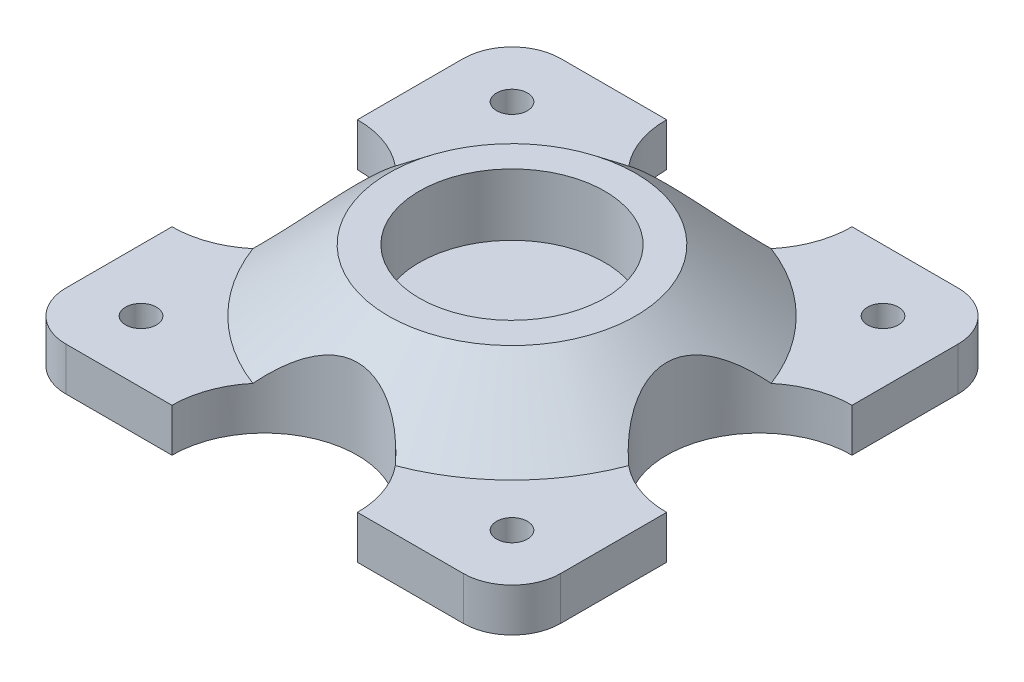
from build123d import *

# Parameters (mm, degrees)
BOSS_EXTRUDE1_DEPTH = 8.89
SKETCH3_R           = 19.05
SKETCH3_R_2         = 3.175
CUT_EXTRUDE1_DEPTH  = 22.59
SKETCH4_R           = 19.05
BOSS_EXTRUDE3_DEPTH = 8.89


with BuildPart() as part:
    # Sketch1 → Boss-Extrude1 (new body)
    with BuildSketch(Plane(origin=(0, 0, 0), x_dir=(1, 0, 0), z_dir=(0, 1, 0))):
        with BuildLine():
            Line((40.8, 50.8), (-40.8, 50.8))
            ThreePointArc((-40.8, 50.8), (-47.871067812, 47.871067812), (-50.8, 40.8))
            Line((-50.8, 40.8), (-50.8, -40.8))
            ThreePointArc((-50.8, -40.8), (-47.871067812, -47.871067812), (-40.8, -50.8))
            Line((-40.8, -50.8), (40.8, -50.8))
            ThreePointArc((40.8, -50.8), (47.871067812, -47.871067812), (50.8, -40.8))
            Line((50.8, -40.8), (50.8, 40.8))
            ThreePointArc((50.8, 40.8), (47.871067812, 47.871067812), (40.8, 50.8))
        make_face()
    extrude(amount=BOSS_EXTRUDE1_DEPTH)

    # Sketch2 → Revolve1 (revolve)
    with BuildSketch(Plane.XY):
        Polygon((0, 8.89), (0, 21.59), (-25.4, 21.59), (-41.28, 8.89), align=None)
    revolve(axis=Axis((0, 8.89, 0), (0, 1, 0)))

    # Sketch3 → Cut-Extrude1 (cut, through all)
    with BuildSketch(Plane(origin=(0, 21.59, 0), x_dir=(1, 0, 0), z_dir=(0, 1, 0))):
        Circle(SKETCH3_R)
        with Locations((-38.1, 38.1)):
            Circle(SKETCH3_R_2)
        with Locations((38.1, 38.1)):
            Circle(SKETCH3_R_2)
        with Locations((38.1, -38.1)):
            Circle(SKETCH3_R_2)
        with Locations((-38.1, -38.1)):
            Circle(SKETCH3_R_2)
        with BuildLine():
            Line((-50.8, 19.05), (-50.8, -19.05))
            ThreePointArc((-50.8, -19.05), (-31.75, 0), (-50.8, 19.05))
        make_face()
        with BuildLine():
            Line((-19.05, 50.8), (19.05, 50.8))
            ThreePointArc((19.05, 50.8), (0, 31.75), (-19.05, 50.8))
        make_face()
        with BuildLine():
            Line((50.8, 19.05), (50.8, -19.05))
            ThreePointArc((50.8, -19.05), (31.75, 0), (50.8, 19.05))
        make_face()
        with BuildLine():
            Line((-19.05, -50.8), (19.05, -50.8))
            ThreePointArc((19.05, -50.8), (0, -31.75), (-19.05, -50.8))
        make_face()
    extrude(amount=-CUT_EXTRUDE1_DEPTH, mode=Mode.SUBTRACT)

    # Sketch4 → Boss-Extrude3 (add)
    with BuildSketch(Plane.XZ):
        Circle(SKETCH4_R)
    extrude(amount=-BOSS_EXTRUDE3_DEPTH)


solid = part.part
